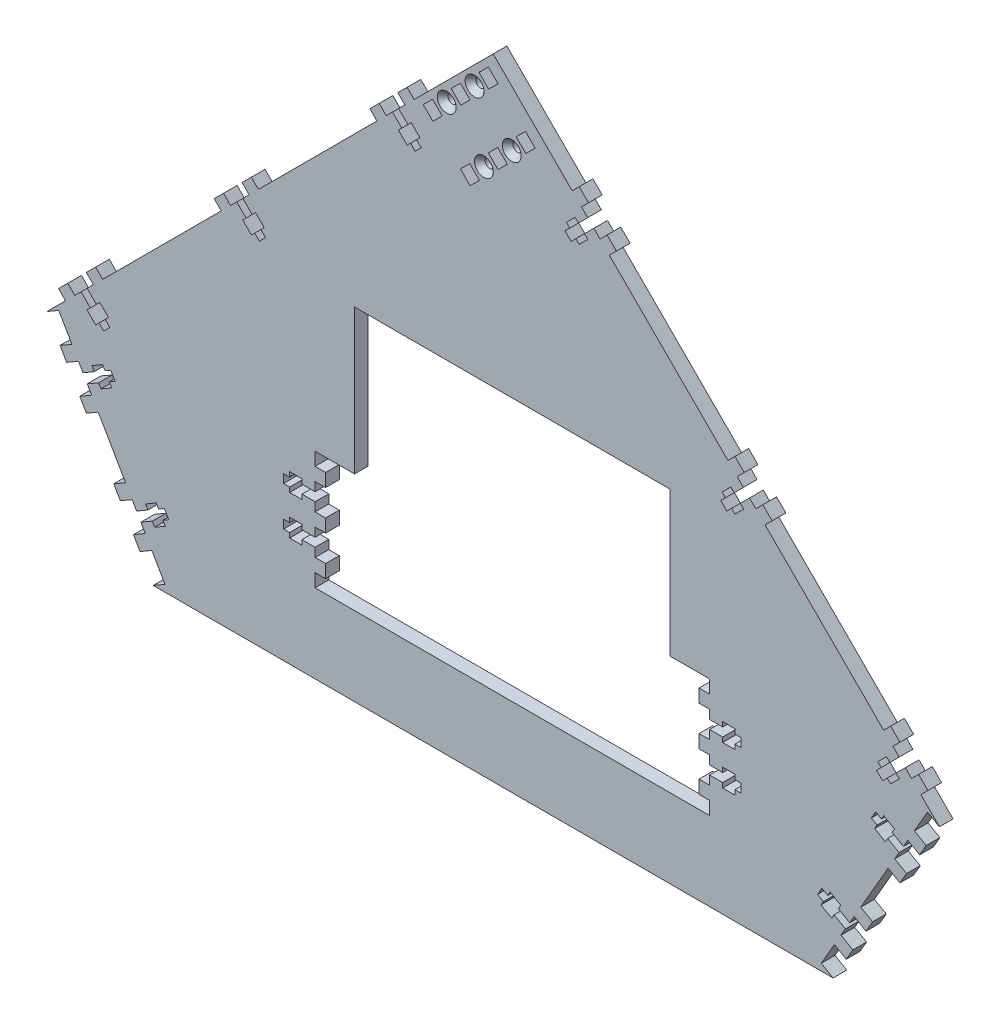
from build123d import *

# Parameters (mm, degrees)
BOSS_EXTRUDE1_DEPTH                               = 6.604
CUT_EXTRUDE1_DEPTH                                = 374.05550758
CUT_EXTRUDE2_DEPTH                                = 374.05550758
SKETCH8_R                                         = 2.15265
CUT_EXTRUDE4_DEPTH                                = 374.05550758
CUT_EXTRUDE3_DEPTH                                = 374.05550758
SKETCH7_W                                         = 5.08
SKETCH7_H                                         = 6.35
BOSS_EXTRUDE2_DEPTH                               = 6.604
MOVE_FACE2_BY                                     = 1.778
MOVE_FACE2_2_BY                                   = 1.778
MOVE_FACE2_3_BY                                   = 1.778
MOVE_FACE2_4_BY                                   = 1.778
MOVE_FACE2_5_BY                                   = 1.778
MOVE_FACE2_6_BY                                   = 1.778
MOVE_FACE2_7_BY                                   = 1.778
MOVE_FACE2_8_BY                                   = 1.778
CSK_FOR_8_FLAT_HEAD_SOCKET_CAP_SCREW1_D           = 4.3053
CSK_FOR_8_FLAT_HEAD_SOCKET_CAP_SCREW1_CSINK_D     = 9.1186
CSK_FOR_8_FLAT_HEAD_SOCKET_CAP_SCREW1_CSINK_ANGLE = 82


with BuildPart() as part:
    # Sketch1 → Boss-Extrude1 (new body)
    with BuildSketch(Plane.XY):
        Polygon((0, 304.426146906), (215.526146906, 88.9), (164.199707975, 0), (0, 0), (-164.199707975, 0), (-215.526146906, 88.9), align=None)
    extrude(amount=BOSS_EXTRUDE1_DEPTH)

    # Sketch2 → Cut-Extrude1 (cut, through all)
    with BuildSketch(Plane.XY.offset(6.604)):
        Polygon((-66.955389821, 165.1), (85.444610179, 165.1), (85.444610179, 95.25), (104.494610179, 95.25), (104.494610179, 38.1), (85.444610179, 38.1), (-66.955389821, 38.1), (-86.005389821, 38.1), (-86.005389821, 95.25), (-66.955389821, 95.25), align=None)
    extrude(amount=-CUT_EXTRUDE1_DEPTH, mode=Mode.SUBTRACT)

    # Sketch3 → Cut-Extrude2 (cut, through all)
    with BuildSketch(Plane.XY.offset(6.604)):
        Polygon((-209.806915139, 92.202), (-215.526146906, 88.9), (-164.199707975, 0), (-158.480476208, 3.302), align=None)
        Polygon((158.480476208, 3.302), (209.806915139, 92.202), (215.526146906, 88.9), (164.199707975, 0), align=None)
    extrude(amount=-CUT_EXTRUDE2_DEPTH, mode=Mode.SUBTRACT)

    # Sketch8 → Cut-Extrude4 (cut, through all)
    with BuildSketch(Plane.XY.offset(6.604)):
        with Locations((-22.450640303, 272.995250482)):
            Circle(SKETCH8_R)
        with Locations((-8.980256121, 286.465634664)):
            Circle(SKETCH8_R)
        with Locations((-4.490128061, 255.03473824)):
            Circle(SKETCH8_R)
        with Locations((8.980256121, 268.505122421)):
            Circle(SKETCH8_R)
        Polygon((-20.295378834, 279.820245134), (-15.805250773, 284.310373194), (-11.13551759, 279.640640012), (-15.625645651, 275.150511951), align=None)
        Polygon((-33.765763015, 266.349860952), (-29.275634955, 270.839989013), (-24.605901772, 266.17025583), (-29.096029832, 261.680127769), align=None)
        Polygon((-6.824994652, 293.290629316), (-2.334866591, 297.780757376), (2.334866591, 293.111024193), (-2.155261469, 288.620896133), align=None)
        Polygon((-2.334866591, 261.859732892), (2.155261469, 266.349860952), (6.824994652, 261.680127769), (2.334866591, 257.189999709), align=None)
        Polygon((-15.805250773, 248.38934871), (-11.315122713, 252.879476771), (-6.64538953, 248.209743588), (-11.13551759, 243.719615527), align=None)
        Polygon((11.13551759, 275.330117073), (15.625645651, 279.820245134), (20.295378834, 275.150511951), (15.805250773, 270.66038389), align=None)
    extrude(amount=-CUT_EXTRUDE4_DEPTH, mode=Mode.SUBTRACT)

    # Sketch6 → Cut-Extrude3 (cut, through all)
    with BuildSketch(Plane.XY.offset(6.604)):
        Polygon((-41.183454571, 254.262436213), (-45.673582632, 258.752564274), (-48.619106639, 255.807040266), (-44.128978579, 251.316912206), (-45.745424681, 249.700466104), (-41.542664816, 245.497706239), (-39.926218714, 247.114152341), (-37.663194172, 244.851127798), (-34.717670164, 247.796651806), (-36.980694707, 250.059676349), (-35.364248605, 251.67612245), (-39.567008469, 255.878882315), align=None)
        Polygon((-116.393099585, 179.052791199), (-120.883227646, 183.54291926), (-123.828751653, 180.597395252), (-119.338623593, 176.107267192), (-120.955069695, 174.49082109), (-116.75230983, 170.288061225), (-115.135863728, 171.904507327), (-112.872839186, 169.641482785), (-109.927315178, 172.587006792), (-112.190339721, 174.850031335), (-110.573893619, 176.466477437), (-114.776653483, 180.669237301), align=None)
        Polygon((-199.038396667, 105.387750238), (-194.548268607, 100.897622178), (-196.164714709, 99.281176076), (-191.961954844, 95.078416211), (-190.345508742, 96.694862313), (-188.0824842, 94.431837771), (-185.136960192, 97.377361778), (-187.399984734, 99.640386321), (-185.783538633, 101.256832423), (-189.986298497, 105.459592287), (-191.602744599, 103.843146185), (-196.09287266, 108.333274246), align=None)
        Polygon((-192.649053825, 75.183712455), (-198.148315139, 72.008712455), (-196.065515139, 68.401197033), (-190.566253825, 71.576197033), (-189.423253825, 69.59646296), (-184.275945235, 72.56826296), (-185.418945235, 74.547997033), (-182.647317533, 76.148197033), (-184.730117533, 79.755712455), (-187.501745235, 78.155512455), (-188.644745235, 80.135246528), (-193.792053825, 77.163446528), align=None)
        Polygon((-166.722614894, 30.277802967), (-172.221876208, 27.102802967), (-170.139076208, 23.495287545), (-164.639814894, 26.670287545), (-163.496814894, 24.690553472), (-158.349506304, 27.662353472), (-159.492506304, 29.642087545), (-156.720878602, 31.242287545), (-158.803678602, 34.849802967), (-161.575306304, 33.249602967), (-162.718306304, 35.22933704), (-167.865614894, 32.25753704), align=None)
        Polygon((39.567008469, 255.878882315), (35.364248605, 251.67612245), (36.980694707, 250.059676349), (34.717670164, 247.796651806), (37.663194172, 244.851127798), (39.926218714, 247.114152341), (41.542664816, 245.497706239), (45.745424681, 249.700466104), (44.128978579, 251.316912206), (48.619106639, 255.807040266), (45.673582632, 258.752564274), (41.183454571, 254.262436213), align=None)
        Polygon((120.883227646, 183.54291926), (116.393099585, 179.052791199), (114.776653483, 180.669237301), (110.573893619, 176.466477437), (112.190339721, 174.850031335), (109.927315178, 172.587006792), (112.872839186, 169.641482785), (115.135863728, 171.904507327), (116.75230983, 170.288061225), (120.955069695, 174.49082109), (119.338623593, 176.107267192), (123.828751653, 180.597395252), align=None)
        Polygon((194.548268607, 100.897622178), (199.038396667, 105.387750238), (196.09287266, 108.333274246), (191.602744599, 103.843146185), (189.986298497, 105.459592287), (185.783538633, 101.256832423), (187.399984734, 99.640386321), (185.136960192, 97.377361778), (188.0824842, 94.431837771), (190.345508742, 96.694862313), (191.961954844, 95.078416211), (196.164714709, 99.281176076), align=None)
        Polygon((188.644745235, 80.135246528), (187.501745235, 78.155512455), (184.730117533, 79.755712455), (182.647317533, 76.148197033), (185.418945235, 74.547997033), (184.275945235, 72.56826296), (189.423253825, 69.59646296), (190.566253825, 71.576197033), (196.065515139, 68.401197033), (198.148315139, 72.008712455), (192.649053825, 75.183712455), (193.792053825, 77.163446528), align=None)
        Polygon((161.575306304, 33.249602967), (158.803678602, 34.849802967), (156.720878602, 31.242287545), (159.492506304, 29.642087545), (158.349506304, 27.662353472), (163.496814894, 24.690553472), (164.639814894, 26.670287545), (170.139076208, 23.495287545), (172.221876208, 27.102802967), (166.722614894, 30.277802967), (167.865614894, 32.25753704), (162.718306304, 35.22933704), align=None)
        Polygon((-86.005389821, 78.2828), (-92.355389821, 78.2828), (-92.355389821, 80.5688), (-98.298989821, 80.5688), (-98.298989821, 78.2828), (-101.245389821, 78.2828), (-101.245389821, 74.1172), (-98.298989821, 74.1172), (-98.298989821, 71.8312), (-92.355389821, 71.8312), (-92.355389821, 74.1172), (-86.005389821, 74.1172), align=None)
        Polygon((-86.005389821, 59.2328), (-92.355389821, 59.2328), (-92.355389821, 61.5188), (-98.298989821, 61.5188), (-98.298989821, 59.2328), (-101.245389821, 59.2328), (-101.245389821, 55.0672), (-98.298989821, 55.0672), (-98.298989821, 52.7812), (-92.355389821, 52.7812), (-92.355389821, 55.0672), (-86.005389821, 55.0672), align=None)
        Polygon((110.844610179, 78.2828), (104.494610179, 78.2828), (104.494610179, 74.1172), (110.844610179, 74.1172), (110.844610179, 71.8312), (116.788210179, 71.8312), (116.788210179, 74.1172), (119.734610179, 74.1172), (119.734610179, 78.2828), (116.788210179, 78.2828), (116.788210179, 80.5688), (110.844610179, 80.5688), align=None)
        Polygon((116.788210179, 61.5188), (110.844610179, 61.5188), (110.844610179, 59.2328), (104.494610179, 59.2328), (104.494610179, 55.0672), (110.844610179, 55.0672), (110.844610179, 52.7812), (116.788210179, 52.7812), (116.788210179, 55.0672), (119.734610179, 55.0672), (119.734610179, 59.2328), (116.788210179, 59.2328), align=None)
    extrude(amount=-CUT_EXTRUDE3_DEPTH, mode=Mode.SUBTRACT)

    # Sketch7 → Boss-Extrude2 (add)
    with BuildSketch(Plane.XY.offset(6.604)):
        Polygon((-41.578585841, 269.672555717), (-38.166088515, 266.260058391), (-42.656216575, 261.769930331), (-46.068713901, 265.182427657), align=None)
        Polygon((-51.636472696, 252.78967421), (-55.048970022, 256.202171536), (-59.539098083, 251.712043475), (-56.126600757, 248.299546149), align=None)
        Polygon((-116.788230855, 194.462910703), (-113.375733528, 191.050413377), (-117.865861589, 186.560285317), (-121.278358915, 189.972782643), align=None)
        Polygon((-126.84611771, 177.580029196), (-130.258615036, 180.992526522), (-134.748743097, 176.502398461), (-131.336245771, 173.089901135), align=None)
        Polygon((-191.997875868, 119.253265689), (-188.585378542, 115.840768363), (-193.075506603, 111.350640303), (-196.488003929, 114.763137629), align=None)
        Polygon((-202.055762724, 102.370384182), (-205.46826005, 105.782881508), (-209.958388111, 101.292753447), (-206.545890785, 97.880256121), align=None)
        Polygon((-207.636353738, 78.790477372), (-203.456915139, 81.203477372), (-200.281915139, 75.704216058), (-204.461353738, 73.291216058), align=None)
        Polygon((-193.931915139, 64.70569343), (-198.111353738, 62.29269343), (-194.936353738, 56.793432116), (-190.756915139, 59.206432116), align=None)
        Polygon((-181.709914807, 33.884567884), (-177.530476208, 36.297567884), (-174.355476208, 30.79830657), (-178.534914807, 28.38530657), align=None)
        Polygon((-168.005476208, 19.799783942), (-172.184914807, 17.386783942), (-169.009914807, 11.887522628), (-164.830476208, 14.300522628), align=None)
        Polygon((169.009914807, 11.887522628), (164.830476208, 14.300522628), (168.005476208, 19.799783942), (172.184914807, 17.386783942), align=None)
        Polygon((174.355476208, 30.79830657), (178.534914807, 28.38530657), (181.709914807, 33.884567884), (177.530476208, 36.297567884), align=None)
        Polygon((194.936353738, 56.793432116), (190.756915139, 59.206432116), (193.931915139, 64.70569343), (198.111353738, 62.29269343), align=None)
        Polygon((207.636353738, 78.790477372), (203.456915139, 81.203477372), (200.281915139, 75.704216058), (204.461353738, 73.291216058), align=None)
        Polygon((209.958388111, 101.292753447), (206.545890785, 97.880256121), (202.055762724, 102.370384182), (205.46826005, 105.782881508), align=None)
        Polygon((193.075506603, 111.350640303), (196.488003929, 114.763137629), (191.997875868, 119.253265689), (188.585378542, 115.840768363), align=None)
        Polygon((134.748743097, 176.502398461), (131.336245771, 173.089901135), (126.84611771, 177.580029196), (130.258615036, 180.992526522), align=None)
        Polygon((121.278358915, 189.972782643), (116.788230855, 194.462910703), (113.375733528, 191.050413377), (117.865861589, 186.560285317), align=None)
        Polygon((55.048970022, 256.202171536), (59.539098083, 251.712043475), (56.126600757, 248.299546149), (51.636472696, 252.78967421), align=None)
        Polygon((46.068713901, 265.182427657), (41.578585841, 269.672555717), (38.166088515, 266.260058391), (42.656216575, 261.769930331), align=None)
        with Locations((-83.465389821, 85.725)):
            Rectangle(SKETCH7_W, SKETCH7_H)
        with Locations((-83.465389821, 66.675)):
            Rectangle(SKETCH7_W, SKETCH7_H)
        with Locations((-83.465389821, 47.625)):
            Rectangle(SKETCH7_W, SKETCH7_H)
        with Locations((101.954610179, 85.725)):
            Rectangle(SKETCH7_W, SKETCH7_H)
        with Locations((101.954610179, 66.675)):
            Rectangle(SKETCH7_W, SKETCH7_H)
        with Locations((101.954610179, 47.625)):
            Rectangle(SKETCH7_W, SKETCH7_H)
    extrude(amount=-BOSS_EXTRUDE2_DEPTH)

    # Move Face2: a face moved outward by 1.778
    extrude(part.faces().sort_by_distance((-170.597414807, 14.637153285, 3.302))[0], amount=MOVE_FACE2_BY, dir=(-0.866025404, -0.5, 0))

    # Move Face2 2: a face moved outward by 1.778
    extrude(part.faces().sort_by_distance((-180.122414807, 31.134937227, 3.302))[0], amount=MOVE_FACE2_2_BY, dir=(-0.866025404, -0.5, 0))

    # Move Face2 3: a face moved outward by 1.778
    extrude(part.faces().sort_by_distance((-196.523853738, 59.543062773, 3.302))[0], amount=MOVE_FACE2_3_BY, dir=(-0.866025404, -0.5, 0))

    # Move Face2 4: a face moved outward by 1.778
    extrude(part.faces().sort_by_distance((-206.048853738, 76.040846715, 3.302))[0], amount=MOVE_FACE2_4_BY, dir=(-0.866025404, -0.5, 0))

    # Move Face2 5: a face moved outward by 1.778
    extrude(part.faces().sort_by_distance((170.597414807, 14.637153285, 3.302))[0], amount=MOVE_FACE2_5_BY, dir=(0.866025404, -0.5, 0))

    # Move Face2 6: a face moved outward by 1.778
    extrude(part.faces().sort_by_distance((180.122414807, 31.134937227, 3.302))[0], amount=MOVE_FACE2_6_BY, dir=(0.866025404, -0.5, 0))

    # Move Face2 7: a face moved outward by 1.778
    extrude(part.faces().sort_by_distance((196.523853738, 59.543062773, 3.302))[0], amount=MOVE_FACE2_7_BY, dir=(0.866025404, -0.5, 0))

    # Move Face2 8: a face moved outward by 1.778
    extrude(part.faces().sort_by_distance((206.048853738, 76.040846715, 3.302))[0], amount=MOVE_FACE2_8_BY, dir=(0.866025404, -0.5, 0))

    # CSK for #8 Flat Head Socket Cap Screw1 (through all)
    with Locations(Plane.XY.offset(6.604)):
        with Locations((-8.980256121, 286.465634664), (8.980256121, 268.505122421), (-4.490128061, 255.03473824), (-22.450640303, 272.995250482)):
            CounterSinkHole(CSK_FOR_8_FLAT_HEAD_SOCKET_CAP_SCREW1_D / 2, CSK_FOR_8_FLAT_HEAD_SOCKET_CAP_SCREW1_CSINK_D / 2, counter_sink_angle=CSK_FOR_8_FLAT_HEAD_SOCKET_CAP_SCREW1_CSINK_ANGLE)


solid = part.part
